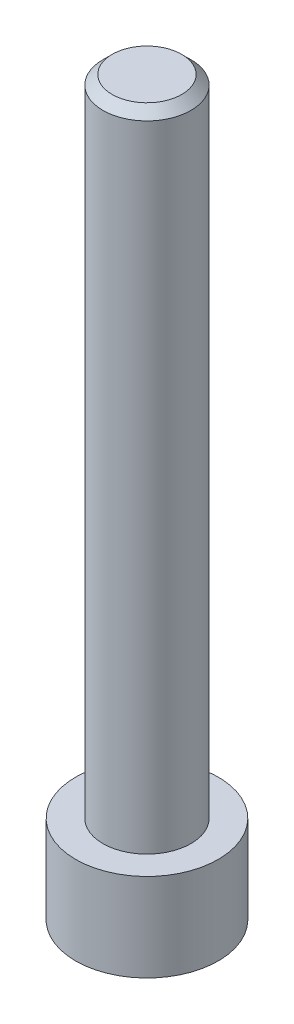
from build123d import *

# Parameters (mm, degrees)
SKETCH1_R           = 3.875
BOSS_EXTRUDE1_DEPTH = 39.78
SKETCH2_OUTSIDE_W   = 18.002
SKETCH2_OUTSIDE_H   = 18.002
SKETCH2_OUTSIDE_R   = 2.39
CUT_EXTRUDE1_DEPTH  = 35
CHAMFER1_SIZE       = 0.5
CUT_EXTRUDE2_DEPTH  = 3.36


with BuildPart() as part:
    # Sketch1 → Boss-Extrude1 (new body)
    with BuildSketch(Plane(origin=(0, 0, 0), x_dir=(1, 0, 0), z_dir=(0, 1, 0))):
        Circle(SKETCH1_R)
    extrude(amount=BOSS_EXTRUDE1_DEPTH)

    # Sketch2 outside → Cut-Extrude1 (cut)
    with BuildSketch(Plane(origin=(0, 39.78, 0), x_dir=(1, 0, 0), z_dir=(0, 1, 0))):
        Rectangle(SKETCH2_OUTSIDE_W, SKETCH2_OUTSIDE_H)
        Circle(SKETCH2_OUTSIDE_R, mode=Mode.SUBTRACT)
    extrude(amount=-CUT_EXTRUDE1_DEPTH, mode=Mode.SUBTRACT)

    # Chamfer1
    chamfer1_edges = [part.edges().sort_by_distance(p)[0] for p in [
        (-2.39, 39.78, 0),
    ]]
    chamfer(chamfer1_edges, length=CHAMFER1_SIZE)

    # Sketch8 → Cut-Extrude2 (cut)
    with BuildSketch(Plane.XZ):
        Polygon((2.644264233, 0), (1.322132116, 2.29), (-1.322132116, 2.29), (-2.644264233, 0), (-1.322132116, -2.29), (1.322132116, -2.29), align=None)
    extrude(amount=-CUT_EXTRUDE2_DEPTH, mode=Mode.SUBTRACT)


solid = part.part
